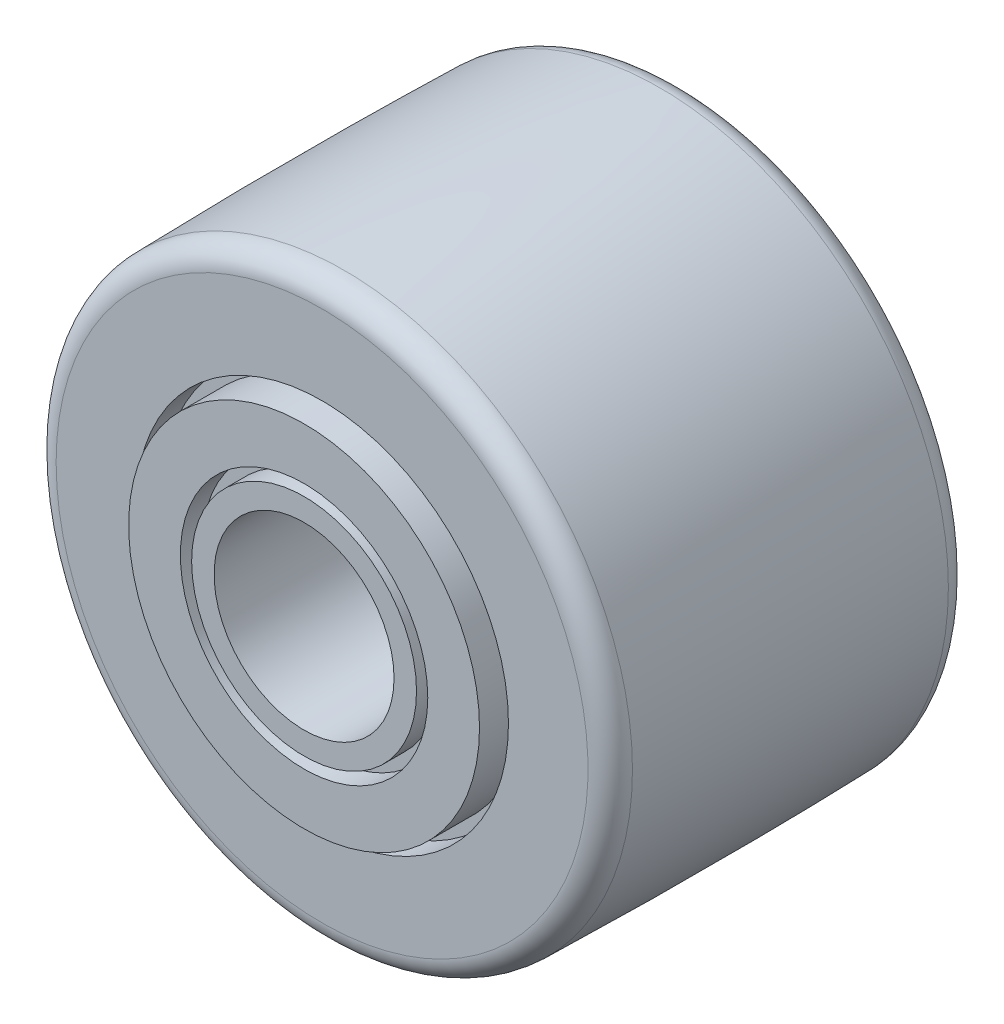
from build123d import *

# Parameters (mm, degrees)
SKETCH2_R          = 3.96875
CUT_EXTRUDE1_DEPTH = 26.155347309
SKETCH3_R          = 5.45703125
SKETCH3_R_2        = 4.9609375
CUT_EXTRUDE2_DEPTH = 0.992188
CUT_EXTRUDE3_START = -1.190625
SKETCH4_R          = 8.222753906
SKETCH4_R_2        = 7.7390625
CUT_EXTRUDE3_DEPTH = 1.190625
FILLET1_R          = 0.9921875


with BuildPart() as part:
    # Sketch1 → Revolve1 (revolve)
    with BuildSketch(Plane(origin=(0, 0, 0), x_dir=(0, 0, -1), z_dir=(1, 0, 0)), mode=Mode.PRIVATE) as revolve1_sk:
        with BuildLine():
            Line((0, 7.7390625), (0.79375, 7.7390625))
            Line((0.79375, 7.7390625), (0.79375, 12.7))
            ThreePointArc((0.79375, 12.7), (8.73125, 12.803370393), (16.66875, 12.7))
            Line((16.66875, 12.7), (16.66875, 7.7390625))
            Line((16.66875, 7.7390625), (17.4625, 7.7390625))
            Line((17.4625, 7.7390625), (17.4625, 0))
            Line((17.4625, 0), (0, 0))
            Line((0, 0), (0, 7.7390625))
        make_face()
    revolve(revolve1_sk.sketch.rotate(Axis((0, 0, 0), (0, 0, -1)), 90), axis=Axis((0, 0, 0), (0, 0, -1)))

    # Sketch2 → Cut-Extrude1 (cut, through all)
    with BuildSketch(Plane.XY):
        Circle(SKETCH2_R)
    extrude(amount=-CUT_EXTRUDE1_DEPTH, mode=Mode.SUBTRACT)

    # Sketch3 → Cut-Extrude2 (cut)
    with BuildSketch(Plane.XY):
        Circle(SKETCH3_R)
        Circle(SKETCH3_R_2, mode=Mode.SUBTRACT)
    cut_extrude2 = extrude(amount=-CUT_EXTRUDE2_DEPTH, mode=Mode.SUBTRACT)

    # Sketch4 → Cut-Extrude3 (cut)
    with BuildSketch(Plane.XY.offset(-0.79375).offset(CUT_EXTRUDE3_START)):
        Circle(SKETCH4_R)
        Circle(SKETCH4_R_2, mode=Mode.SUBTRACT)
    cut_extrude3 = extrude(amount=CUT_EXTRUDE3_DEPTH, mode=Mode.SUBTRACT)

    # Fillet1
    fillet1_edges = [part.edges().sort_by_distance(p)[0] for p in [
        (-12.7, 0, -16.66875),
        (-12.7, 0, -0.79375),
    ]]
    fillet(fillet1_edges, radius=FILLET1_R)

    # Mirror1: Cut-Extrude2, Cut-Extrude3 across plane
    add(cut_extrude2.mirror(Plane.XY.offset(-8.73125)), mode=Mode.SUBTRACT)
    add(cut_extrude3.mirror(Plane.XY.offset(-8.73125)), mode=Mode.SUBTRACT)


solid = part.part
